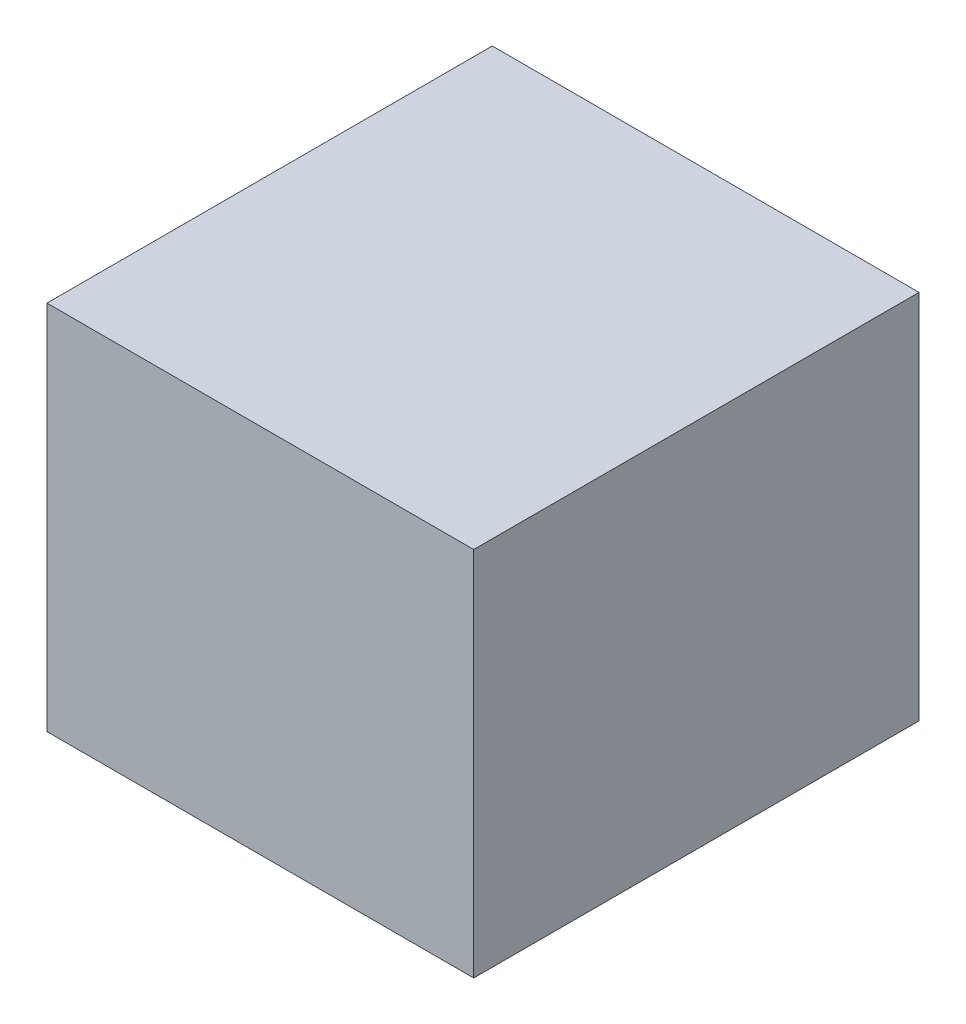
from build123d import *

# Parameters (mm, degrees)
SKETCH_1_W      = 600
SKETCH_1_H      = 500
EXTRUDE_1_DEPTH = 287.5


with BuildPart() as part:
    # 草圖1 → 填料-伸長1 (new body, symmetric)
    with BuildSketch(Plane(origin=(0, 0, 0), x_dir=(0, 0, -1), z_dir=(1, 0, 0))):
        Rectangle(SKETCH_1_W, SKETCH_1_H)
    extrude(amount=EXTRUDE_1_DEPTH, both=True)


solid = part.part
